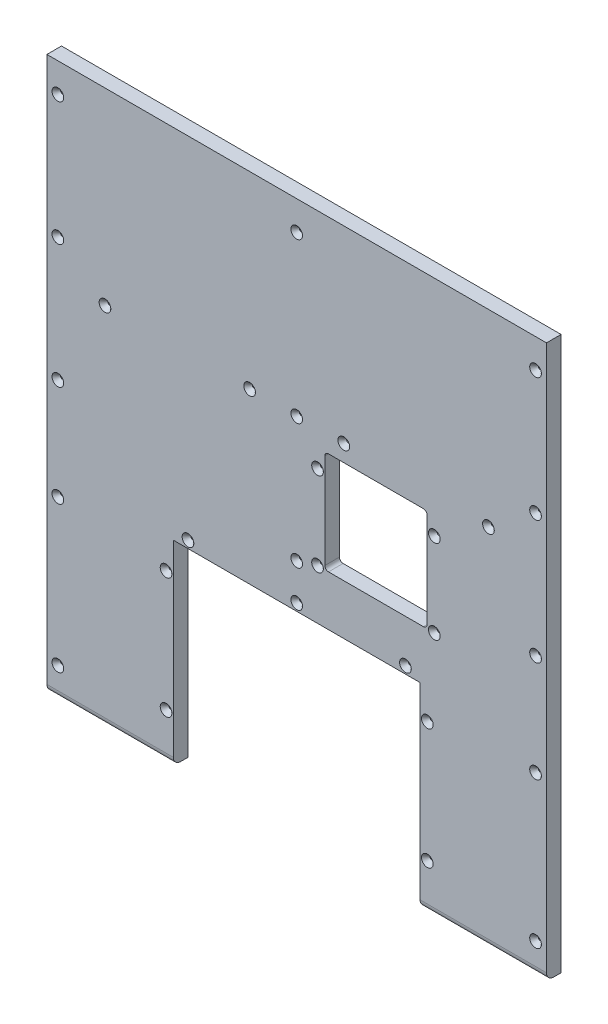
from build123d import *

# Parameters (mm, degrees)
BOSS_EXTRUDE1_DEPTH = 12.7
FILLET1_R           = 6.35
HOLE1_D             = 3.175
HOLE1_DEPTH         = 12.7
HOLE1_CSINK_D       = 10.16
HOLE1_CSINK_ANGLE   = 82
HOLE1_TIP           = 0.953866233
HOLE2_D             = 3.175
HOLE2_DEPTH         = 31.75
HOLE2_CSINK_D       = 10.16
HOLE2_CSINK_ANGLE   = 82
HOLE2_TIP           = 0.953866233
CUT_EXTRUDE1_REACH  = 14.7
SKETCH6_W           = 88.9
SKETCH6_H           = 88.9
FILLET2_R           = 3.175
HOLE3_D             = 3.175
HOLE3_DEPTH         = 31.75
HOLE3_CSINK_D       = 10.16
HOLE3_CSINK_ANGLE   = 82
HOLE3_TIP           = 0.953866233


with BuildPart() as part:
    # Sketch1 → Boss-Extrude1 (new body)
    with BuildSketch(Plane.XY):
        Polygon((16.704465975, -230.262851166), (-93.295534025, -230.262851166), (-93.295534025, 250.666642396), (341.304465963, 250.666642396), (341.304465963, -230.262851166), (231.304465963, -230.262851166), (231.304465963, -60.262851166), (16.704465975, -60.262851166), align=None)
    extrude(amount=-BOSS_EXTRUDE1_DEPTH)

    # Fillet1
    fillet1_edges = [part.edges().sort_by_distance(p)[0] for p in [
        (286.304465963, -230.262851166, 0),
        (-38.295534025, -230.262851166, 0),
    ]]
    fillet(fillet1_edges, radius=FILLET1_R)

    # Hole1
    with Locations(Plane.XY):
        with Locations((218.604465963, -53.912851166), (331.779465963, -204.862851166), (331.779465963, 10.201895615), (331.779465963, 225.266642396), (331.779465963, 117.734269005), (331.779465963, -77.862851166), (164.983632635, 86.68320968), (290.800299298, 86.68320968), (237.654465963, -86.479517833), (237.654465963, -191.3461845), (124.004465969, 86.68320968), (124.004465969, 225.266642396), (124.004465969, -22.162851166), (10.354465975, -191.3461845), (10.354465975, -86.479517833), (-42.791367359, 86.68320968), (83.025299304, 86.68320968), (-83.770534025, -77.862851166), (-83.770534025, 117.734269005), (-83.770534025, 225.266642396), (-83.770534025, 10.201895615), (-83.770534025, -204.862851166), (124.004465969, -53.912851166), (29.404465975, -53.912851166)):
            CounterSinkHole(HOLE1_D / 2, HOLE1_CSINK_D / 2, depth=HOLE1_DEPTH, counter_sink_angle=HOLE1_CSINK_ANGLE)
            with Locations((0, 0, -(HOLE1_DEPTH + HOLE1_TIP / 2))):  # 118° drill point
                Cone(0, HOLE1_D / 2, HOLE1_TIP, mode=Mode.SUBTRACT)

    # Hole2
    with Locations(Plane(origin=(124.004465969, -215.287141225, 0), x_dir=(1, 0, 0), z_dir=(0, 0, 1))):
        with Locations((113.649999994, 128.807623392), (113.649999994, 23.940956725), (-94.599999994, 161.374290059), (94.599999994, 161.374290059), (0, 161.374290059), (0, 193.124290059), (0, 440.553783621), (0, 301.970350905), (40.979166666, 301.970350905), (166.795833328, 301.970350905), (207.774999994, 440.553783621), (207.774999994, 333.02141023), (207.774999994, 225.48903684), (207.774999994, 137.424290059), (207.774999994, 10.424290059), (-207.774999994, 10.424290059), (-207.774999994, 137.424290059), (-207.774999994, 225.48903684), (-207.774999994, 333.02141023), (-207.774999994, 440.553783621), (-166.795833328, 301.970350905), (-40.979166666, 301.970350905), (-113.649999994, 23.940956725), (-113.649999994, 128.807623392)):
            CounterSinkHole(HOLE2_D / 2, HOLE2_CSINK_D / 2, depth=HOLE2_DEPTH, counter_sink_angle=HOLE2_CSINK_ANGLE)
            with Locations((0, 0, -(HOLE2_DEPTH + HOLE2_TIP / 2))):  # 118° drill point
                Cone(0, HOLE2_D / 2, HOLE2_TIP, mode=Mode.SUBTRACT)

    # Sketch6 → Cut-Extrude1 (cut, up to next)
    with BuildSketch(Plane.XY, mode=Mode.PRIVATE) as cut_extrude1_sk1:
        with Locations((192.927465963, 27.76820968)):
            Rectangle(SKETCH6_W, SKETCH6_H)
    cut_extrude1_tool1 = extrude(cut_extrude1_sk1.sketch, amount=-CUT_EXTRUDE1_REACH, mode=Mode.PRIVATE) & part.part
    add(cut_extrude1_tool1.solids().sort_by_distance((192.927466, 27.76821, 0))[0], mode=Mode.SUBTRACT)

    # Fillet2
    fillet2_edges = [part.edges().sort_by_distance(p)[0] for p in [
        (148.477465963, -16.68179032, -6.35),
        (148.477465963, 72.21820968, -6.35),
        (237.377465963, 72.21820968, -6.35),
        (237.377465963, -16.68179032, -6.35),
    ]]
    fillet(fillet2_edges, radius=FILLET2_R)

    # Hole3
    with Locations(Plane(origin=(124.004465969, -215.287141225, 0), x_dir=(1, 0, 0), z_dir=(0, 0, 1))):
        with Locations((113.649999994, 128.807623392), (113.649999994, 23.940956725), (-94.599999994, 161.374290059), (94.599999994, 161.374290059), (0, 161.374290059), (0, 193.124290059), (0, 440.553783621), (0, 301.970350905), (40.979166666, 301.970350905), (166.795833328, 301.970350905), (207.774999994, 440.553783621), (207.774999994, 333.02141023), (207.774999994, 225.48903684), (207.774999994, 137.424290059), (207.774999994, 10.424290059), (-207.774999994, 10.424290059), (-207.774999994, 137.424290059), (-207.774999994, 225.48903684), (-207.774999994, 333.02141023), (-207.774999994, 440.553783621), (-166.795833328, 301.970350905), (-40.979166666, 301.970350905), (-113.649999994, 23.940956725), (-113.649999994, 128.807623392), (119.722999994, 198.605350905), (119.722999994, 271.630350905), (18.122999994, 198.605350905), (18.122999994, 271.630350905)):
            CounterSinkHole(HOLE3_D / 2, HOLE3_CSINK_D / 2, depth=HOLE3_DEPTH, counter_sink_angle=HOLE3_CSINK_ANGLE)
            with Locations((0, 0, -(HOLE3_DEPTH + HOLE3_TIP / 2))):  # 118° drill point
                Cone(0, HOLE3_D / 2, HOLE3_TIP, mode=Mode.SUBTRACT)


solid = part.part
